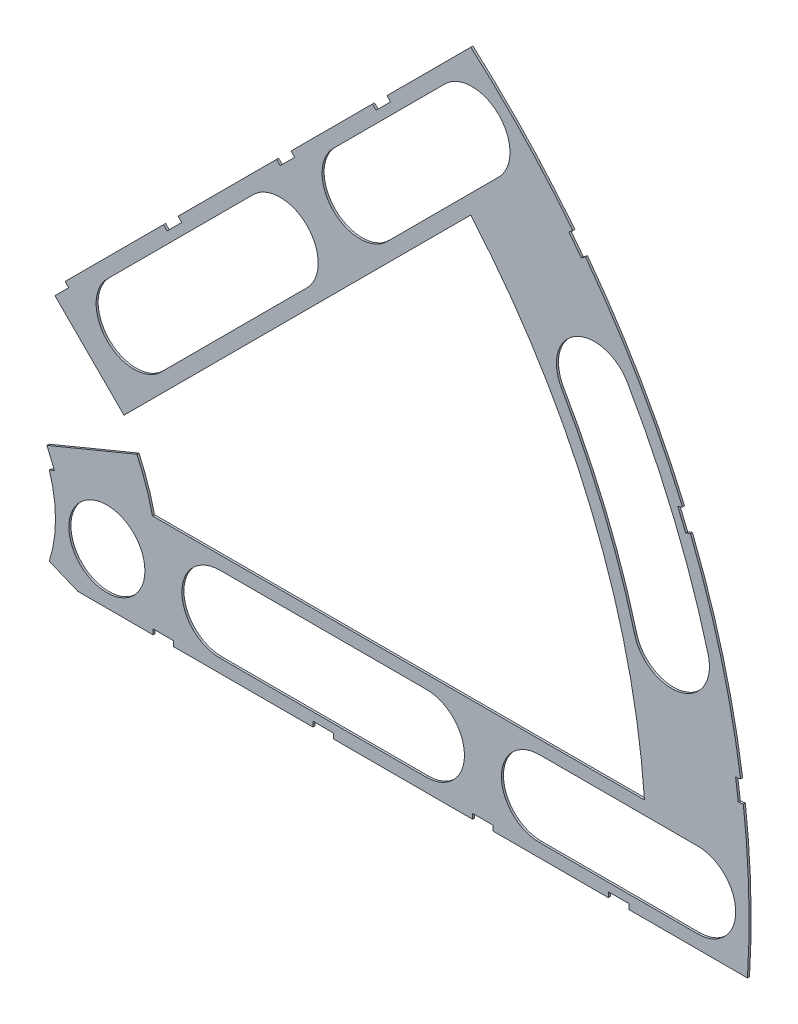
from build123d import *

# Parameters (mm, degrees)
BOSS_EXTRUDE1_DEPTH = 0.254
SKETCH2_R           = 4.699
CUT_EXTRUDE1_DEPTH  = 1.254
SKETCH3_W           = 2.54
SKETCH3_H           = 0.635
CUT_EXTRUDE2_DEPTH  = 1.254
CUT_EXTRUDE4_DEPTH  = 1.254
CUT_EXTRUDE5_DEPTH  = 1.254


with BuildPart() as part:
    # Sketch1 → Boss-Extrude1 (new body)
    with BuildSketch(Plane.XY):
        with BuildLine():
            Line((67.21146711, 76.191723231), (8.696654013, 17.676910134))
            Line((8.696654013, 17.676910134), (7.228954972, 14.133571205))
            ThreePointArc((7.228954972, 14.133571205), (14.666587579, 6.075099489), (15.105587123, -4.88230096))
            Line((15.105587123, -4.88230096), (18.648926052, -6.35))
            Line((18.648926052, -6.35), (101.401368334, -6.35))
            ThreePointArc((101.401368334, -6.35), (93.866160503, 38.880636728), (67.21146711, 76.191723231))
        make_face()
        with BuildLine():
            Line((88.672924278, 6.35), (27.86051193, 6.35))
            ThreePointArc((27.86051193, 6.35), (26.399857642, 10.93517908), (24.190484974, 15.210228852))
            Line((24.190484974, 15.210228852), (67.191354125, 58.211098004))
            ThreePointArc((67.191354125, 58.211098004), (82.13289044, 34.020557137), (88.672924278, 6.35))
        make_face(mode=Mode.SUBTRACT)
    extrude(amount=BOSS_EXTRUDE1_DEPTH)

    # Sketch2 → Cut-Extrude1 (cut, through all)
    with BuildSketch(Plane.XY.offset(0.254)):
        with Locations((22.225, 0)):
            Circle(SKETCH2_R)
        with Locations((36.195, 0)):
            Circle(SKETCH2_R)
        with Locations((61.722, 0)):
            Circle(SKETCH2_R)
        with Locations((75.692, 0)):
            Circle(SKETCH2_R)
        with Locations((95.25, 0)):
            Circle(SKETCH2_R)
        with Locations((15.715448212, 15.715448212)):
            Circle(SKETCH2_R)
        with Locations((25.593729945, 25.593729945)):
            Circle(SKETCH2_R)
        with Locations((43.644044748, 43.644044748)):
            Circle(SKETCH2_R)
        with Locations((53.522326482, 53.522326482)):
            Circle(SKETCH2_R)
        with Locations((92.004434954, 24.652514046)):
            Circle(SKETCH2_R)
        with Locations((82.48891971, 47.625)):
            Circle(SKETCH2_R)
        with Locations((67.351920908, 67.351920908)):
            Circle(SKETCH2_R)
    extrude(amount=-CUT_EXTRUDE1_DEPTH, mode=Mode.SUBTRACT)

    # Sketch3 → Cut-Extrude2 (cut, through all)
    with BuildSketch(Plane.XY.offset(0.254)):
        Polygon((15.266435406, 24.246691527), (17.06248663, 26.042742751), (17.511499436, 25.593729945), (15.715448212, 23.797678721), align=None)
        Polygon((44.991083167, 53.971339288), (43.195031942, 52.175288063), (43.644044748, 51.726275257), (45.440095973, 53.522326482), align=None)
        with Locations((29.21, -6.0325)):
            Rectangle(SKETCH3_W, SKETCH3_H)
        with Locations((68.707, -6.0325)):
            Rectangle(SKETCH3_W, SKETCH3_H)
        Polygon((29.230733674, 38.210989795), (31.026784898, 40.007041019), (31.475797704, 39.558028213), (29.67974648, 37.761976989), align=None)
        Polygon((56.845021246, 65.825277367), (55.048970022, 64.029226143), (55.497982828, 63.580213337), (57.294034052, 65.376264561), align=None)
        with Locations((48.9585, -6.0325)):
            Rectangle(SKETCH3_W, SKETCH3_H)
        with Locations((85.471, -6.0325)):
            Rectangle(SKETCH3_W, SKETCH3_H)
        Polygon((99.935462164, 14.437711971), (100.266998693, 11.919442024), (101.526133667, 12.085210288), (101.194597138, 14.603480236), align=None)
        Polygon((93.765504959, 37.464305742), (94.938831965, 37.950313702), (93.966816047, 40.296967714), (92.793489041, 39.810959755), align=None)
        Polygon((79.327792988, 62.471156422), (80.874047017, 60.456038938), (81.88160576, 61.229165953), (80.33535173, 63.244283437), align=None)
        Polygon((13.593916116, 7.005422516), (14.565932035, 4.658768503), (15.739259041, 5.144776462), (14.767243123, 7.491430475), align=None)
    extrude(amount=-CUT_EXTRUDE2_DEPTH, mode=Mode.SUBTRACT)

    # Sketch6 → Cut-Extrude4 (cut, through all)
    with BuildSketch(Plane.XY.offset(0.254)):
        with BuildLine():
            Line((22.27103518, 28.91642471), (40.321349984, 46.966739513))
            ThreePointArc((40.321349984, 46.966739513), (46.966739513, 46.966739513), (46.966739513, 40.321349984))
            Line((46.966739513, 40.321349984), (28.91642471, 22.27103518))
            ThreePointArc((28.91642471, 22.27103518), (22.27103518, 22.27103518), (22.27103518, 28.91642471))
        make_face()
        with BuildLine():
            Line((50.199631717, 56.845021246), (64.029226143, 70.674615673))
            ThreePointArc((64.029226143, 70.674615673), (70.674615673, 70.674615673), (70.674615673, 64.029226143))
            Line((70.674615673, 64.029226143), (56.845021246, 50.199631717))
            ThreePointArc((56.845021246, 50.199631717), (50.199631717, 50.199631717), (50.199631717, 56.845021246))
        make_face()
        with BuildLine():
            Line((61.722, -4.699), (36.195, -4.699))
            ThreePointArc((36.195, -4.699), (31.496, 0), (36.195, 4.699))
            Line((36.195, 4.699), (61.722, 4.699))
            ThreePointArc((61.722, 4.699), (66.421, 0), (61.722, -4.699))
        make_face()
        with BuildLine():
            Line((95.25, -4.699), (75.692, -4.699))
            ThreePointArc((75.692, -4.699), (70.993, 0), (75.692, 4.699))
            Line((75.692, 4.699), (95.25, 4.699))
            ThreePointArc((95.25, 4.699), (99.949, 0), (95.25, -4.699))
        make_face()
        with BuildLine():
            ThreePointArc((96.543320412, 25.868704739), (92.340835395, 38.248826381), (86.558373083, 49.9745))
            ThreePointArc((86.558373083, 49.9745), (80.13941971, 51.694453372), (78.419466338, 45.2755))
            ThreePointArc((78.419466338, 45.2755), (83.658215548, 34.652367484), (87.465549496, 23.436323353))
            ThreePointArc((87.465549496, 23.436323353), (93.220625647, 20.113628588), (96.543320412, 25.868704739))
        make_face()
    extrude(amount=-CUT_EXTRUDE4_DEPTH, mode=Mode.SUBTRACT)

    # Sketch5 → Cut-Extrude5 (cut, through all)
    with BuildSketch(Plane.XY.offset(0.254)):
        Polygon((8.418953573, 4.724419036), (27.192185674, 12.500546382), (12.82377588, 26.868956175), (-0.450903843, 13.594276452), align=None)
    extrude(amount=-CUT_EXTRUDE5_DEPTH, mode=Mode.SUBTRACT)


solid = part.part
